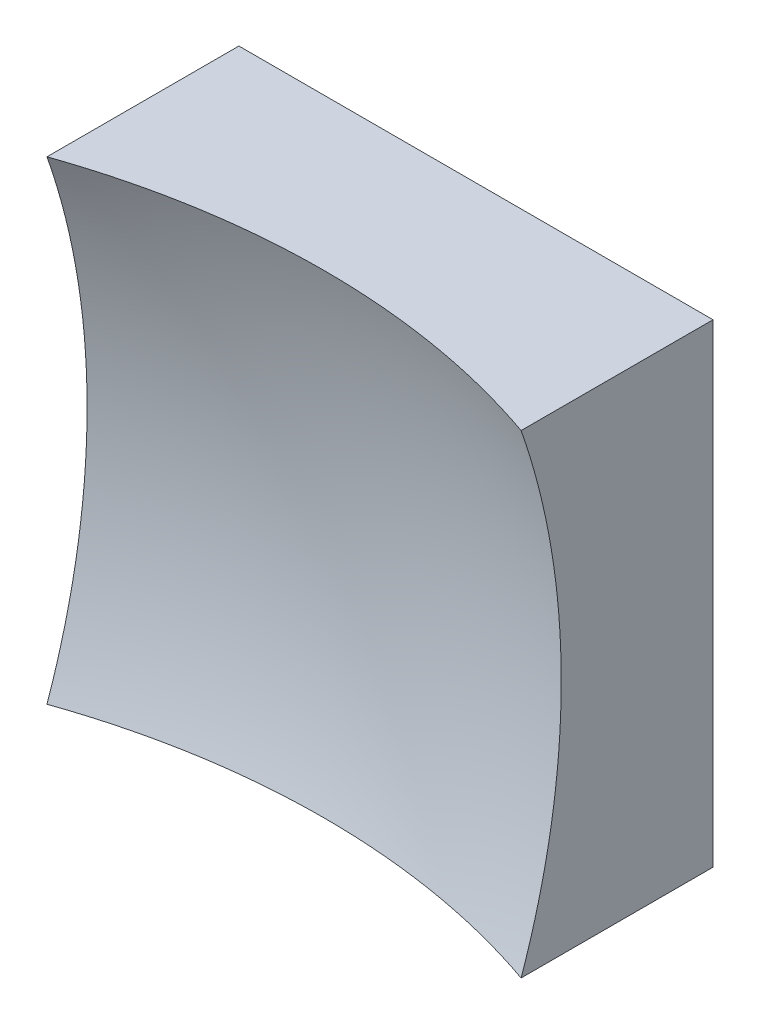
from build123d import *

# Parameters (mm, degrees)
SKETCH_1_W      = 12.5
SKETCH_1_H      = 12.5
EXTRUDE_1_DEPTH = 10


with BuildPart() as part:
    # 草图1 → 凸台-拉伸1 (new body)
    with BuildSketch(Plane.XY):
        Rectangle(SKETCH_1_W, SKETCH_1_H)
    extrude(amount=EXTRUDE_1_DEPTH)

    # 草图2 → 切除-旋转2 (revolve, cut)
    with BuildSketch(Plane(origin=(0, 0, 0), x_dir=(1, 0, 0), z_dir=(0, 1, 0))):
        with BuildLine():
            Line((19.496909236, -18.542362707), (0, -18.542362707))
            Line((0, -18.542362707), (0, -3))
            ThreePointArc((0, -3), (12.466901262, -7.361062283), (19.496909236, -18.542362707))
        make_face()
    revolve(axis=Axis((0, 0, 18.542362707), (0, 0, -1)), mode=Mode.SUBTRACT)


solid = part.part
